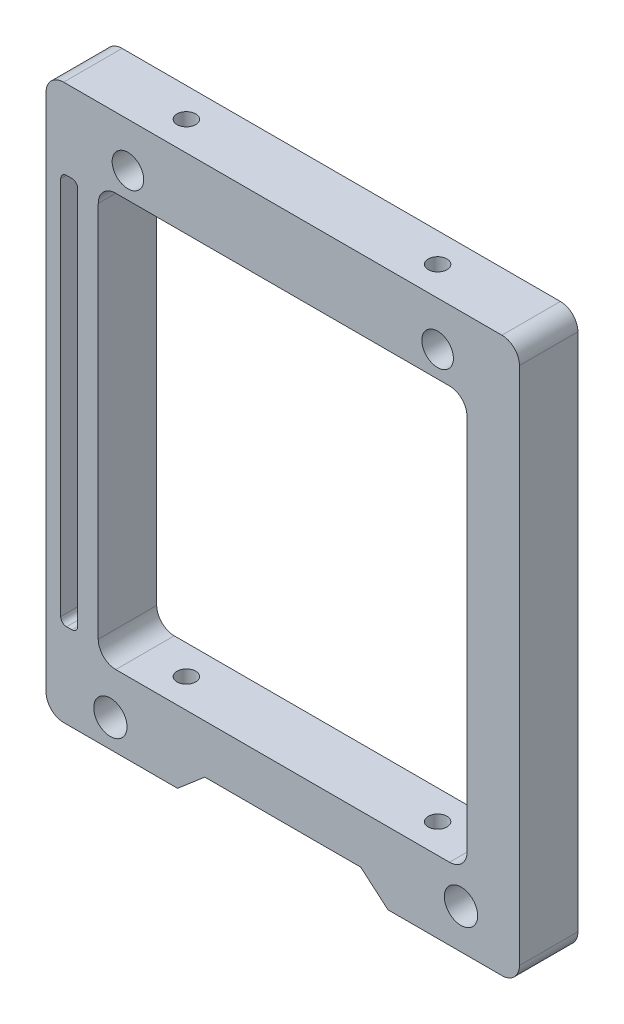
from build123d import *

# Parameters (mm, degrees)
SKETCH_2_W          = 63.086066497
SKETCH_2_H          = 70.564750697
SKETCH_2_R          = 2.7
SKETCH_2_R_2        = 2.85
EXTRUDE_1_DEPTH     = 10
SKETCH_6_R          = 1.6
CUT_EXTRUDE_1_DEPTH = 95.878321509
CUT_EXTRUDE_2_DEPTH = 10
FILLET_1_R          = 3
FILLET_2_R          = 3
FILLET_3_R          = 3
FILLET_4_R          = 3
FILLET_5_R          = 3
FILLET_6_R          = 3


with BuildPart() as part:
    # Эскиз2 → Бобышка-Вытянуть1 (new body)
    with BuildSketch(Plane.XY):
        Polygon((80.980294199, 100.097628386), (0, 100.097628386), (0, 5.219306877), (22.4901471, 5.219306877), (27.153223736, 9.209358448), (53.827070463, 9.209358448), (58.4901471, 5.219306877), (80.980294199, 5.219306877), align=None)
        with Locations((40.466269796, 52.815253038)):
            Rectangle(SKETCH_2_W, SKETCH_2_H, mode=Mode.SUBTRACT)
        with Locations((14, 92.5)):
            Circle(SKETCH_2_R, mode=Mode.SUBTRACT)
        with Locations((66.980294199, 92.5)):
            Circle(SKETCH_2_R, mode=Mode.SUBTRACT)
        with Locations((70.980294199, 12)):
            Circle(SKETCH_2_R_2, mode=Mode.SUBTRACT)
        with Locations((11, 10)):
            Circle(SKETCH_2_R_2, mode=Mode.SUBTRACT)
    extrude(amount=EXTRUDE_1_DEPTH)

    # Эскиз6 → Вырез-Вытянуть1 (cut, through all)
    with BuildSketch(Plane(origin=(0, 100.097628386, 0), x_dir=(1, 0, 0), z_dir=(0, 1, 0))):
        with Locations((19, -5)):
            Circle(SKETCH_6_R)
        with Locations((61.980294199, -5)):
            Circle(SKETCH_6_R)
    extrude(amount=-CUT_EXTRUDE_1_DEPTH, mode=Mode.SUBTRACT)

    # Эскиз7 → Вырез-Вытянуть2 (cut)
    with BuildSketch(Plane.XY.offset(10)):
        with BuildLine():
            Line((3.501352047, 86.531809887), (4.413826334, 86.531809887))
            ThreePointArc((4.413826334, 86.531809887), (5.120933115, 86.238916668), (5.413826334, 85.531809887))
            Line((5.413826334, 85.531809887), (5.413826334, 20.671530594))
            ThreePointArc((5.413826334, 20.671530594), (5.120933115, 19.964423813), (4.413826334, 19.671530594))
            Line((4.413826334, 19.671530594), (3.501352047, 19.671530594))
            ThreePointArc((3.501352047, 19.671530594), (2.794245266, 19.964423813), (2.501352047, 20.671530594))
            Line((2.501352047, 20.671530594), (2.501352047, 85.531809887))
            ThreePointArc((2.501352047, 85.531809887), (2.794245266, 86.238916668), (3.501352047, 86.531809887))
        make_face()
    extrude(amount=-CUT_EXTRUDE_2_DEPTH, mode=Mode.SUBTRACT)

    # Скругление1
    fillet_1_edges = [part.edges().sort_by_distance(p)[0] for p in [
        (72.009303044, 88.097628386, 5),
    ]]
    fillet(fillet_1_edges, radius=FILLET_1_R)

    # Скругление2
    fillet_2_edges = [part.edges().sort_by_distance(p)[0] for p in [
        (8.923236547, 88.097628386, 5),
    ]]
    fillet(fillet_2_edges, radius=FILLET_2_R)

    # Скругление3
    fillet_3_edges = [part.edges().sort_by_distance(p)[0] for p in [
        (8.923236547, 17.532877689, 5),
    ]]
    fillet(fillet_3_edges, radius=FILLET_3_R)

    # Скругление4
    fillet_4_edges = [part.edges().sort_by_distance(p)[0] for p in [
        (72.009303044, 17.532877689, 5),
    ]]
    fillet(fillet_4_edges, radius=FILLET_4_R)

    # Скругление5
    fillet_5_edges = [part.edges().sort_by_distance(p)[0] for p in [
        (0, 100.097628386, 5),
        (80.980294199, 100.097628386, 5),
    ]]
    fillet(fillet_5_edges, radius=FILLET_5_R)

    # Скругление6
    fillet_6_edges = [part.edges().sort_by_distance(p)[0] for p in [
        (80.980294199, 5.219306877, 5),
        (0, 5.219306877, 5),
    ]]
    fillet(fillet_6_edges, radius=FILLET_6_R)


solid = part.part
